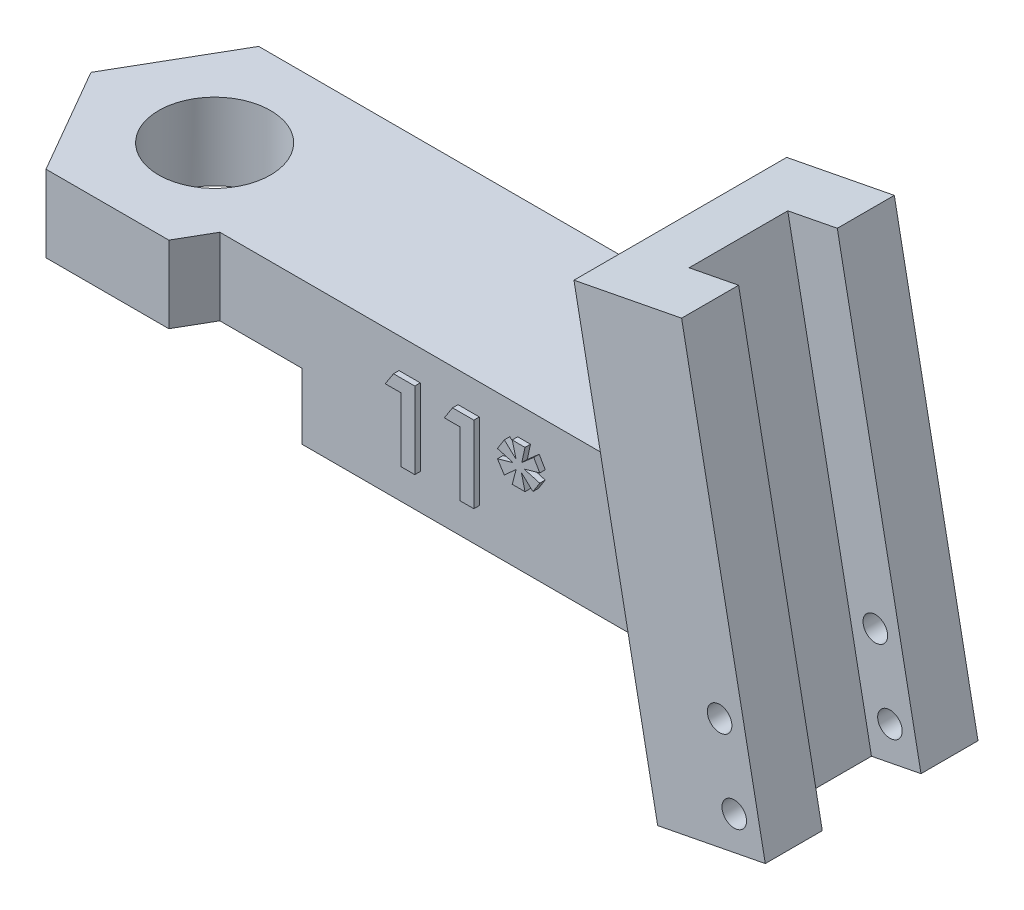
from build123d import *

# Parameters (mm, degrees)
SKETCH1_W                       = 25
SKETCH1_H                       = 6.75
BOSS_EXTRUDE1_DEPTH             = 6.5
BOSS_EXTRUDE4_DEPTH             = 6.5
BOSS_EXTRUDE3_REACH             = 6.85
BOSS_EXTRUDE3_DIRECTION_2_REACH = 6.85
SKETCH4_W                       = 2.3
SKETCH4_H                       = 4.5
CUT_EXTRUDE1_DEPTH              = 23
SKETCH6_R                       = 2.55
CUT_EXTRUDE2_DEPTH              = 10
BOSS_EXTRUDE5_DEPTH             = 1.475
CUT_EXTRUDE3_DEPTH              = 3
SKETCH9_R                       = 0.56
CUT_EXTRUDE4_DEPTH              = 9.7
BOSS_EXTRUDE6_DEPTH             = 0.25


with BuildPart() as part:
    # Sketch1 → Boss-Extrude1 (new body)
    with BuildSketch(Plane(origin=(0, 0, 0), x_dir=(1, 0, 0), z_dir=(0, 1, 0))):
        with Locations((12.5, -3.375)):
            Rectangle(SKETCH1_W, SKETCH1_H)
    extrude(amount=BOSS_EXTRUDE1_DEPTH)

    # Sketch5 → Boss-Extrude4 (add)
    with BuildSketch(Plane(origin=(0, 6.5, 0), x_dir=(1, 0, 0), z_dir=(0, 1, 0))):
        Polygon((-5.600297611, -3.375), (-2.800148806, -8.225), (2.800148806, -8.225), (5.600297611, -3.375), (2.800148806, 1.475), (-2.800148806, 1.475), align=None)
    extrude(amount=-BOSS_EXTRUDE4_DEPTH)

    # Boss-Extrude3: up to this face of the body (flat: up to its plane)
    boss_extrude3_end = Plane(part.part.faces().sort_by_distance((0, 3.25, -1.475))[0])
    # Sketch3 → Boss-Extrude3 (add, up to the picked face)
    with BuildSketch(Plane.XY.offset(3.375), mode=Mode.PRIVATE) as boss_extrude3_sk1:
        Polygon((21.275684175, 14.155521181), (26.183820092, 15.109566157), (30, -4.522977512), (25.091864083, -5.477022488), align=None)
    boss_extrude3_tool1 = split(extrude(boss_extrude3_sk1.sketch, amount=-BOSS_EXTRUDE3_REACH, mode=Mode.PRIVATE), bisect_by=boss_extrude3_end, keep=Keep.BOTH, mode=Mode.PRIVATE)
    add(boss_extrude3_tool1.solids().sort_by_distance((25.637842, 4.816272, 3.375))[0])

    # Boss-Extrude3 direction 2: up to this face of the body (flat: up to its plane)
    boss_extrude3_direction_2_end = Plane(part.part.faces().sort_by_distance((0, 3.25, 8.225))[0])
    # Sketch3 → Boss-Extrude3 direction 2 (add, up to the picked face)
    with BuildSketch(Plane.XY.offset(3.375), mode=Mode.PRIVATE) as boss_extrude3_direction_2_sk1:
        Polygon((21.275684175, 14.155521181), (26.183820092, 15.109566157), (30, -4.522977512), (25.091864083, -5.477022488), align=None)
    boss_extrude3_direction_2_tool1 = split(extrude(boss_extrude3_direction_2_sk1.sketch, amount=BOSS_EXTRUDE3_DIRECTION_2_REACH, mode=Mode.PRIVATE), bisect_by=boss_extrude3_direction_2_end, keep=Keep.BOTH, mode=Mode.PRIVATE)
    add(boss_extrude3_direction_2_tool1.solids().sort_by_distance((25.637842, 4.816272, 3.375))[0])

    # Sketch4 → Cut-Extrude1 (cut)
    with BuildSketch(Plane(origin=(-1.876769127, 9.65514015, 0), x_dir=(0.981627183, 0.190808995, 0), z_dir=(-0.190808995, 0.981627183, 0))):
        with Locations((27.435790708, -3.375)):
            Rectangle(SKETCH4_W, SKETCH4_H)
    extrude(amount=-CUT_EXTRUDE1_DEPTH, mode=Mode.SUBTRACT)

    # Sketch6 → Cut-Extrude2 (cut)
    with BuildSketch(Plane(origin=(0, 6.5, 0), x_dir=(1, 0, 0), z_dir=(0, 1, 0))):
        with Locations((0, -3.335615973)):
            Circle(SKETCH6_R)
    extrude(amount=-CUT_EXTRUDE2_DEPTH, mode=Mode.SUBTRACT)

    # Sketch7 → Boss-Extrude5 (add)
    with BuildSketch(Plane(origin=(0, 0, -1.475), x_dir=(-1, 0, 0), z_dir=(0, 0, -1))):
        Polygon((-2.800148806, 0), (-24.027238758, 0), (-25.091864083, -5.477022488), (-30, -4.522977512), (-26.183820092, 15.109566157), (-21.275684175, 14.155521181), (-22.763766749, 6.5), (-2.800148806, 6.5), align=None)
    extrude(amount=-BOSS_EXTRUDE5_DEPTH)

    # Sketch8 → Cut-Extrude3 (cut)
    with BuildSketch(Plane(origin=(0, 0, 0), x_dir=(-1, 0, 0), z_dir=(0, -1, 0))):
        Polygon((-4.67653718, -11.475), (4.67653718, -11.475), (9.353074361, -3.375), (4.67653718, 4.725), (-4.67653718, 4.725), (-9.353074361, -3.375), align=None)
    extrude(amount=-CUT_EXTRUDE3_DEPTH, mode=Mode.SUBTRACT)

    # Sketch9 → Cut-Extrude4 (cut)
    with BuildSketch(Plane(origin=(0, 0, -1.475), x_dir=(-1, 0, 0), z_dir=(0, 0, -1))):
        with Locations((-28.584915246, -3.269967081)):
            Circle(SKETCH9_R)
        with Locations((-27.917083762, 0.165728061)):
            Circle(SKETCH9_R)
    extrude(amount=-CUT_EXTRUDE4_DEPTH, mode=Mode.SUBTRACT)

    # Sketch10 → Boss-Extrude6 (add)
    with BuildSketch(Plane.XY.offset(6.75)):
        Polygon((11.821517388, 5.121255448), (12.792571074, 5.121255448), (12.792571074, 1.621255448), (12.164365946, 1.621255448), (12.164365946, 4.537922115), (11.446417228, 4.537922115), align=None)
        Polygon((14.513825081, 5.121255448), (15.484878766, 5.121255448), (15.484878766, 1.621255448), (14.856673638, 1.621255448), (14.856673638, 4.537922115), (14.13872492, 4.537922115), align=None)
        Polygon((17.234878766, 5.210999038), (17.8182121, 5.210999038), (17.672378766, 4.537922115), (18.215748157, 5.013983814), (18.491289023, 4.537922115), (17.773340305, 4.335999038), (18.491289023, 4.134075961), (18.180692068, 3.647497435), (17.6541496, 4.134075961), (17.8182121, 3.460999038), (17.234878766, 3.460999038), (17.412262581, 4.134075961), (16.873801042, 3.647497435), (16.561801843, 4.134075961), (17.279750561, 4.335999038), (16.561801843, 4.537922115), (16.873801042, 5.036419711), (17.412262581, 4.537922115), align=None)
    extrude(amount=BOSS_EXTRUDE6_DEPTH)


solid = part.part
